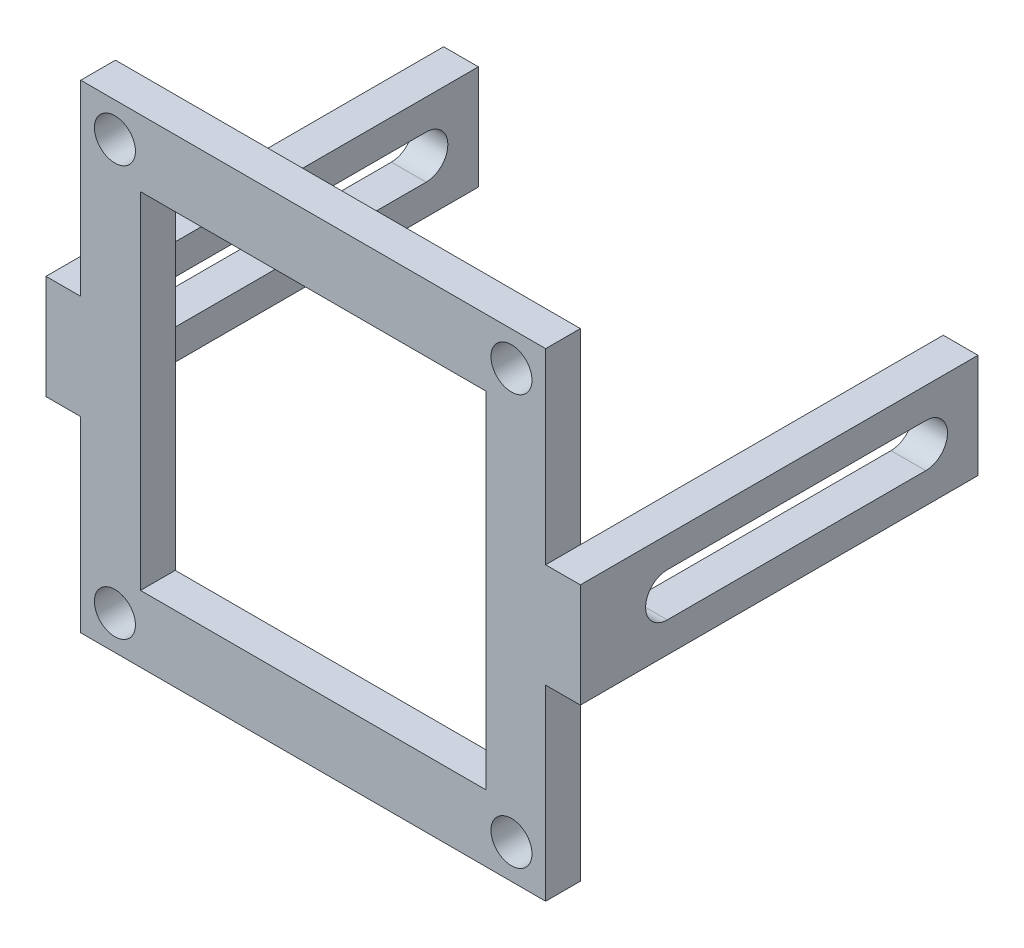
from build123d import *

# Parameters (mm, degrees)
SKETCH1_W           = 34
SKETCH1_H           = 35
SKETCH1_R           = 1.5
SKETCH1_W_2         = 25.254046856
SKETCH1_H_2         = 25.254046855
BOSS_EXTRUDE1_DEPTH = 2.54
BOSS_EXTRUDE2_DEPTH = 2.54


with BuildPart() as part:
    # Sketch1 → Boss-Extrude1 (new body)
    with BuildSketch(Plane.XY.offset(89.71558927)):
        with Locations((0, 15.365074249)):
            Rectangle(SKETCH1_W, SKETCH1_H)
        with Locations((-14.5, 30.365074249)):
            Circle(SKETCH1_R, mode=Mode.SUBTRACT)
        with Locations((14.5, 30.365074249)):
            Circle(SKETCH1_R, mode=Mode.SUBTRACT)
        with Locations((14.5, 0.365074249)):
            Circle(SKETCH1_R, mode=Mode.SUBTRACT)
        with Locations((-14.5, 0.365074249)):
            Circle(SKETCH1_R, mode=Mode.SUBTRACT)
        with Locations((0, 15.36507425)):
            Rectangle(SKETCH1_W_2, SKETCH1_H_2, mode=Mode.SUBTRACT)
    extrude(amount=BOSS_EXTRUDE1_DEPTH)

    # Sketch2 → Boss-Extrude2 (add)
    with BuildSketch(Plane.ZY.offset(17)):
        Polygon((63.176971269, 11.555074249), (89.71558927, 11.555074249), (92.25558927, 11.555074249), (92.25558927, 19.175074249), (89.71558927, 19.175074249), (63.176971269, 19.175074249), align=None)
        with BuildLine():
            Line((66.996602623, 16.952574249), (85.895957916, 16.952574249))
            ThreePointArc((85.895957916, 16.952574249), (87.483457916, 15.365074249), (85.895957916, 13.777574249))
            Line((85.895957916, 13.777574249), (66.996602623, 13.777574249))
            ThreePointArc((66.996602623, 13.777574249), (65.409102623, 15.365074249), (66.996602623, 16.952574249))
        make_face(mode=Mode.SUBTRACT)
    boss_extrude2 = extrude(amount=BOSS_EXTRUDE2_DEPTH)

    # Mirror1: Boss-Extrude2 across plane
    add(boss_extrude2.mirror(Plane(origin=(0, 0, 0), x_dir=(0, 0, 1), z_dir=(1, 0, 0))))


solid = part.part
